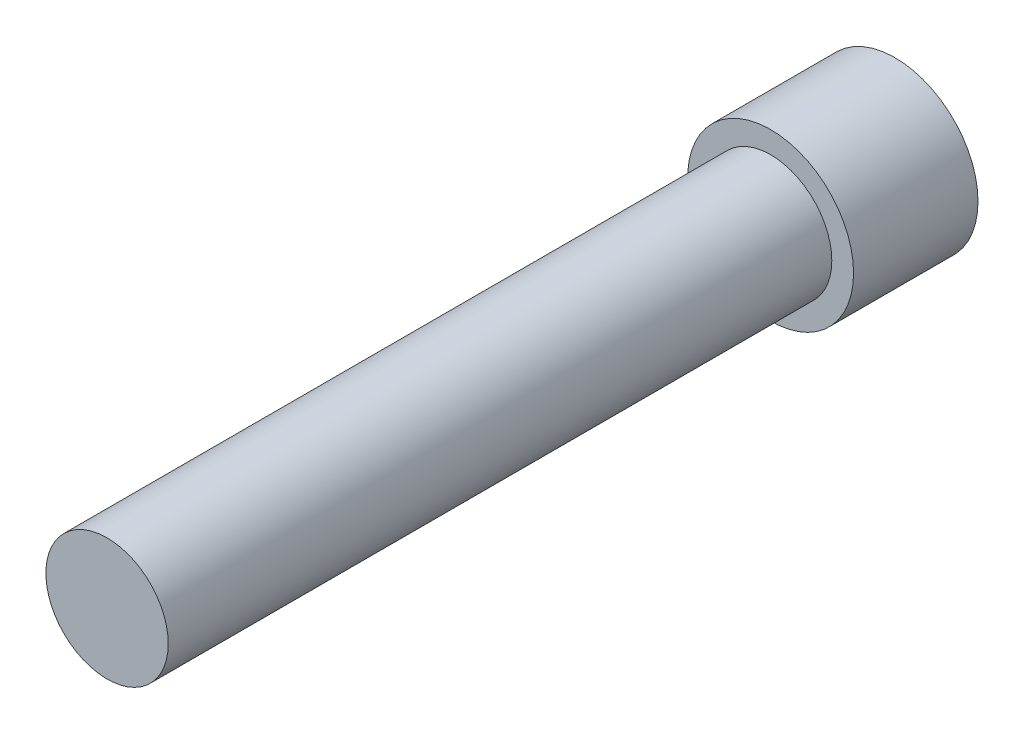
from build123d import *

# Parameters (mm, degrees)
SKETCH1_R      = 2
EXTRUDE1_DEPTH = 3
EXTRUDE3_DEPTH = 1.82
SKETCH2_R      = 1.475
EXTRUDE2_DEPTH = 16


with BuildPart() as part:
    # Sketch1 → Extrude1 (new body)
    with BuildSketch(Plane.XY):
        Circle(SKETCH1_R)
    extrude(amount=EXTRUDE1_DEPTH)

    # Sketch3 → Extrude3 (cut)
    with BuildSketch(Plane(origin=(0, 0, 0), x_dir=(-1, 0, 0), z_dir=(0, 0, -1))):
        Polygon((-1.443375673, 0), (-0.721687836, -1.25), (0.721687836, -1.25), (1.443375673, 0), (0.721687836, 1.25), (-0.721687836, 1.25), align=None)
    extrude(amount=-EXTRUDE3_DEPTH, mode=Mode.SUBTRACT)

    # Sketch2 → Extrude2 (add)
    with BuildSketch(Plane.XY.offset(3)):
        Circle(SKETCH2_R)
    extrude(amount=EXTRUDE2_DEPTH)


solid = part.part
